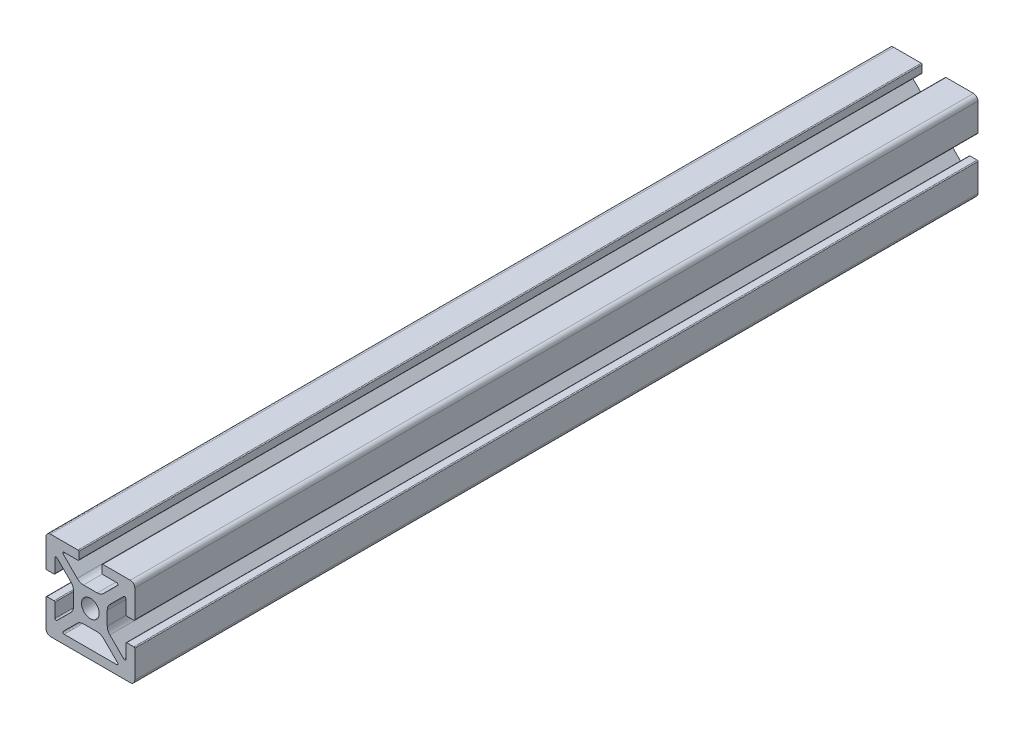
from build123d import *

# Parameters (mm, degrees)
BOSS_EXTRUDE1_DEPTH = 120.65
FILLET2_R           = 0.254
FILLET1_R           = 1.27
SKETCH5_W           = 7.112
SKETCH5_H           = 2.54
BOSS_EXTRUDE2_DEPTH = 241.3


with BuildPart() as part:
    # Sketch3 → Boss-Extrude1 (new body, symmetric)
    with BuildSketch(Plane.XY):
        with BuildLine():
            Line((-12.7, 12.7), (-1.796051224, 1.796051224))
            ThreePointArc((-1.796051224, 1.796051224), (-0.972015918, 2.346654013), (0, 2.54))
            Line((0, 2.54), (0, 4.826))
            Line((0, 4.826), (-1.977846327, 4.826))
            ThreePointArc((-1.977846327, 4.826), (-2.949862246, 5.019345987), (-3.773897552, 5.569948776))
            Line((-3.773897552, 5.569948776), (-7.772528286, 9.56857951))
            ThreePointArc((-7.772528286, 9.56857951), (-7.847628361, 9.946133082), (-7.527553898, 10.16))
            Line((-7.527553898, 10.16), (-3.302, 10.16))
            Line((-3.302, 10.16), (-3.302, 12.7))
            Line((-3.302, 12.7), (-12.7, 12.7))
        make_face()
    extrude(amount=BOSS_EXTRUDE1_DEPTH, both=True)

    # Fillet2
    fillet2_edges = [part.edges().sort_by_distance(p)[0] for p in [
        (-3.302, 12.7, 0),
        (-3.302, 10.16, 0),
    ]]
    fillet(fillet2_edges, radius=FILLET2_R)

    # Mirror1: part across plane


with BuildPart() as part_1:
    add(part.part)
    add(part.part.mirror(Plane(origin=(0, 0, 120.65), x_dir=(0, 0, 1), z_dir=(0.707106781, 0.707106781, 0))))

    # Fillet1
    fillet1_edges = [part_1.edges().sort_by_distance(p)[0] for p in [
        (-12.7, 12.7, 0),
    ]]
    fillet(fillet1_edges, radius=FILLET1_R)

    # Mirror2: part across plane


with BuildPart() as part_2:
    add(part_1.part)
    add(part_1.part.mirror(Plane(origin=(0, 0, 120.65), x_dir=(0, 0, 1), z_dir=(0, 1, 0))))

    # Mirror5: part across plane


with BuildPart() as part_3:
    add(part_2.part)
    add(part_2.part.mirror(Plane(origin=(0, 0, 120.65), x_dir=(0, 0, 1), z_dir=(-1, 0, 0))))

    # Sketch5 → Boss-Extrude2 (add, through all)
    with BuildSketch(Plane.XY.offset(120.65)):
        with Locations((0, -11.43)):
            Rectangle(SKETCH5_W, SKETCH5_H)
    extrude(amount=-BOSS_EXTRUDE2_DEPTH)


solid = part_3.part
